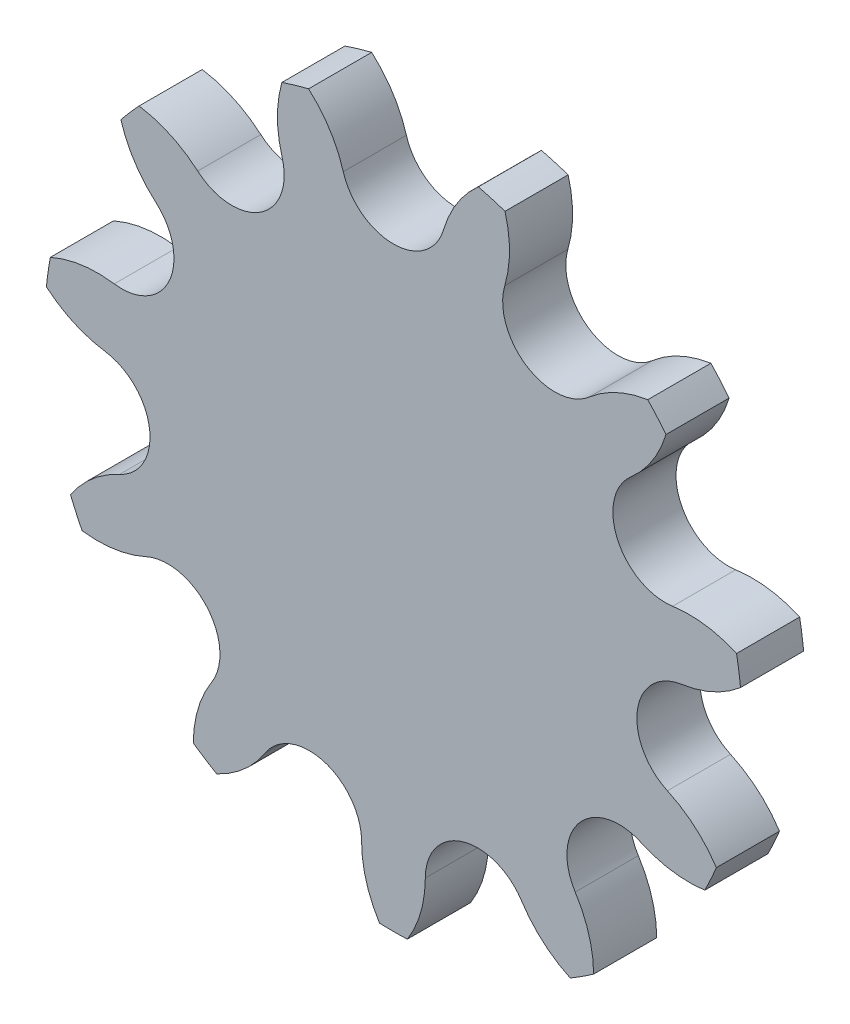
from build123d import *

# Parameters (mm, degrees)
EXTRUDE_1_DEPTH          = 3
PATTERN_CIRCULAR_1_COUNT = 11


with BuildPart() as part:
    # Эскиз2 → Бобышка-Вытянуть1 (new body)
    with BuildSketch(Plane.XY):
        with BuildLine():
            Line((0, 0), (0, 11.712862132))
            ThreePointArc((0, 11.712862132), (1.489205001, 12.208517148), (2.384340039, 13.497756728))
            ThreePointArc((2.384340039, 13.497756728), (3.025331037, 14.908293504), (4.033365809, 16.084877268))
            ThreePointArc((4.033365809, 16.084877268), (4.671932148, 15.911139698), (5.303057959, 15.712062015))
            ThreePointArc((5.303057959, 15.712062015), (5.514961564, 14.177272024), (5.291603749, 12.644107081))
            ThreePointArc((5.291603749, 12.644107081), (5.347623722, 11.075583191), (6.332451358, 9.853486648))
            Line((6.332451358, 9.853486648), (0, 0))
        make_face()
    extrude_1 = extrude(amount=EXTRUDE_1_DEPTH)

    # Круговой массив1: Бобышка-Вытянуть1 ×11 about axis
    pattern_circular_1_axis = Axis((0, 0, 0), (0, 0, 1))
    for i in range(1, PATTERN_CIRCULAR_1_COUNT):
        add(extrude_1.rotate(pattern_circular_1_axis, i * 360 / PATTERN_CIRCULAR_1_COUNT))


solid = part.part
